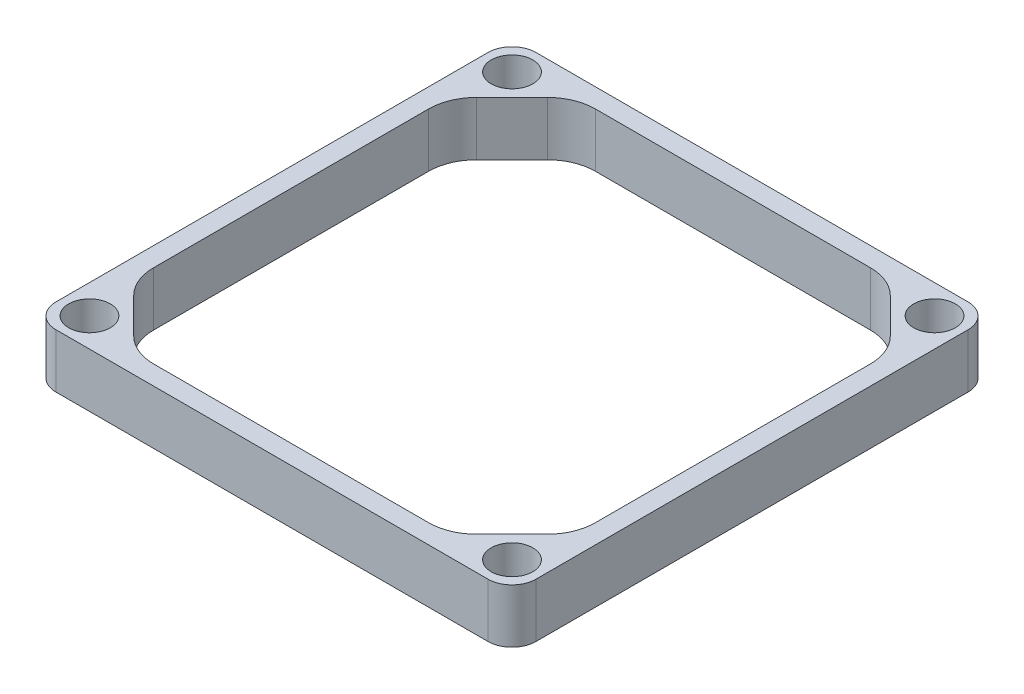
from build123d import *

# Parameters (mm, degrees)
SKETCH1_R                      = 44.45
SKETCH1_R_2                    = 3.25
BOSS_EXTRUDE1_DEPTH            = 3.175
BOSS_EXTRUDE2_DEPTH            = 25.4
CBORE_FOR_M6_SHCS2_D           = 7
CBORE_FOR_M6_SHCS2_CBORE_D     = 11
CBORE_FOR_M6_SHCS2_CBORE_DEPTH = 6
SKETCH10_W                     = 206.275362682
SKETCH10_H                     = 234.398565581
CUT_EXTRUDE1_DEPTH             = 15.2875
CBORE_FOR_M6_SHCS3_D           = 7
CBORE_FOR_M6_SHCS3_CBORE_D     = 11
CBORE_FOR_M6_SHCS3_CBORE_DEPTH = 8.54


with BuildPart() as part:
    # Sketch1 → Boss-Extrude1 (new body)
    with BuildSketch(Plane(origin=(0, 0, 0), x_dir=(1, 0, 0), z_dir=(0, 1, 0))):
        with BuildLine():
            Line((-57.15, 63.5), (57.15, 63.5))
            ThreePointArc((57.15, 63.5), (61.640128061, 61.640128061), (63.5, 57.15))
            Line((63.5, 57.15), (63.5, -57.15))
            ThreePointArc((63.5, -57.15), (61.640128061, -61.640128061), (57.15, -63.5))
            Line((57.15, -63.5), (-57.15, -63.5))
            ThreePointArc((-57.15, -63.5), (-61.640128061, -61.640128061), (-63.5, -57.15))
            Line((-63.5, -57.15), (-63.5, 57.15))
            ThreePointArc((-63.5, 57.15), (-61.640128061, 61.640128061), (-57.15, 63.5))
        make_face()
        Circle(SKETCH1_R, mode=Mode.SUBTRACT)
        with Locations((-57.15, 53.975)):
            Circle(SKETCH1_R_2, mode=Mode.SUBTRACT)
        with Locations((57.15, 53.975)):
            Circle(SKETCH1_R_2, mode=Mode.SUBTRACT)
        with Locations((57.15, -53.975)):
            Circle(SKETCH1_R_2, mode=Mode.SUBTRACT)
        with Locations((-57.15, -53.975)):
            Circle(SKETCH1_R_2, mode=Mode.SUBTRACT)
    extrude(amount=BOSS_EXTRUDE1_DEPTH)

    # Sketch3 → Boss-Extrude2 (add)
    with BuildSketch(Plane(origin=(0, 3.175, 0), x_dir=(1, 0, 0), z_dir=(0, 1, 0))):
        with BuildLine():
            Line((-57.15, -63.5), (57.15, -63.5))
            ThreePointArc((57.15, -63.5), (61.640128061, -61.640128061), (63.5, -57.15))
            Line((63.5, -57.15), (63.5, 57.15))
            ThreePointArc((63.5, 57.15), (61.640128061, 61.640128061), (57.15, 63.5))
            Line((57.15, 63.5), (-57.15, 63.5))
            ThreePointArc((-57.15, 63.5), (-61.640128061, 61.640128061), (-63.5, 57.15))
            Line((-63.5, 57.15), (-63.5, -57.15))
            ThreePointArc((-63.5, -57.15), (-61.640128061, -61.640128061), (-57.15, -63.5))
        make_face()
        with BuildLine():
            Line((-54.700256121, 45.358975516), (-45.358975516, 54.700256121))
            ThreePointArc((-45.358975516, 54.700256121), (-41.238798986, 57.453270063), (-36.378719395, 58.42))
            Line((-36.378719395, 58.42), (36.378719395, 58.42))
            ThreePointArc((36.378719395, 58.42), (41.238798986, 57.453270063), (45.358975516, 54.700256121))
            Line((45.358975516, 54.700256121), (54.700256121, 45.358975516))
            ThreePointArc((54.700256121, 45.358975516), (57.453270063, 41.238798986), (58.42, 36.378719395))
            Line((58.42, 36.378719395), (58.42, -36.378719395))
            ThreePointArc((58.42, -36.378719395), (57.453270063, -41.238798986), (54.700256121, -45.358975516))
            Line((54.700256121, -45.358975516), (45.358975516, -54.700256121))
            ThreePointArc((45.358975516, -54.700256121), (41.238798986, -57.453270063), (36.378719395, -58.42))
            Line((36.378719395, -58.42), (-36.378719395, -58.42))
            ThreePointArc((-36.378719395, -58.42), (-41.238798986, -57.453270063), (-45.358975516, -54.700256121))
            Line((-45.358975516, -54.700256121), (-54.700256121, -45.358975516))
            ThreePointArc((-54.700256121, -45.358975516), (-57.453270063, -41.238798986), (-58.42, -36.378719395))
            Line((-58.42, -36.378719395), (-58.42, 36.378719395))
            ThreePointArc((-58.42, 36.378719395), (-57.453270063, 41.238798986), (-54.700256121, 45.358975516))
        make_face(mode=Mode.SUBTRACT)
    extrude(amount=BOSS_EXTRUDE2_DEPTH)

    # CBORE for M6 SHCS2 (through all)
    with Locations(Plane(origin=(0, 0, 0), x_dir=(-1, 0, 0), z_dir=(0, -1, 0))):
        with Locations((-55.88, 55.88), (55.88, 55.88), (55.88, -55.88), (-55.88, -55.88)):
            CounterBoreHole(CBORE_FOR_M6_SHCS2_D / 2, CBORE_FOR_M6_SHCS2_CBORE_D / 2, CBORE_FOR_M6_SHCS2_CBORE_DEPTH)

    # Sketch10 → Cut-Extrude1 (cut, through all)
    with BuildSketch(Plane(origin=(0, 14.2875, 0), x_dir=(-1, 0, 0), z_dir=(0, -1, 0))):
        with Locations((4.587579463, 2.84706708)):
            Rectangle(SKETCH10_W, SKETCH10_H)
    extrude(amount=CUT_EXTRUDE1_DEPTH, mode=Mode.SUBTRACT)

    # CBORE for M6 SHCS3 (through all)
    with Locations(Plane(origin=(0, 28.575, 0), x_dir=(1, 0, 0), z_dir=(0, 1, 0))):
        with Locations((55.88, 55.88), (55.88, -55.88), (-55.88, -55.88), (-55.88, 55.88)):
            CounterBoreHole(CBORE_FOR_M6_SHCS3_D / 2, CBORE_FOR_M6_SHCS3_CBORE_D / 2, CBORE_FOR_M6_SHCS3_CBORE_DEPTH)


solid = part.part
